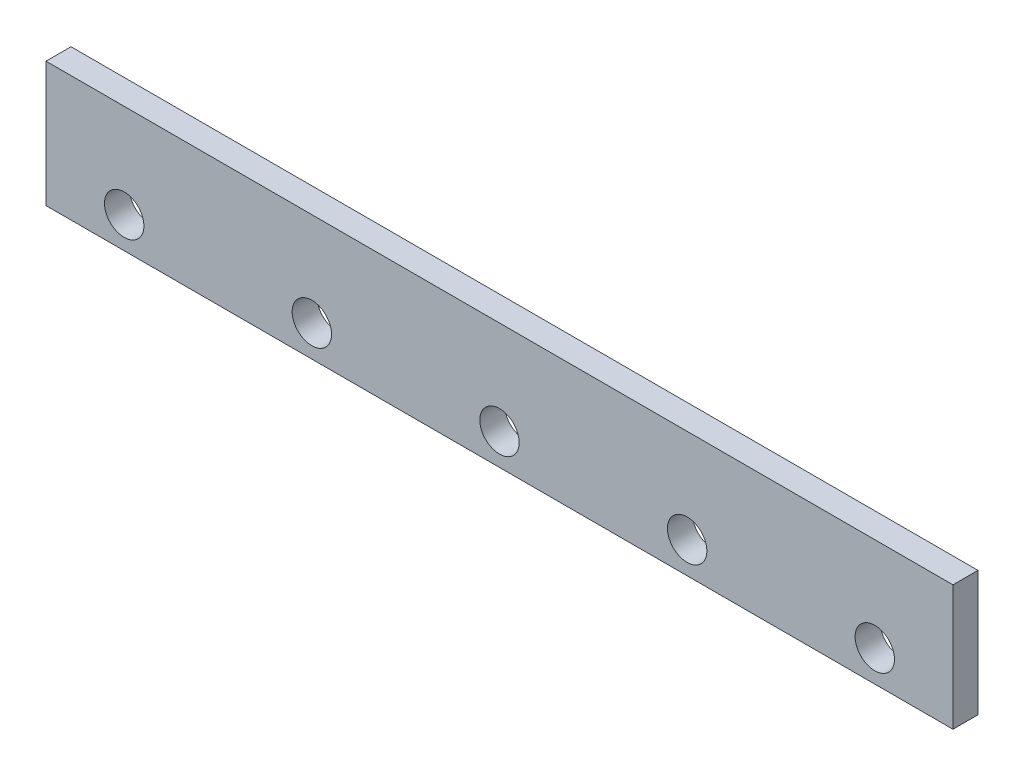
from build123d import *

# Parameters (mm, degrees)
SKETCH1_W           = 580
SKETCH1_H           = 80
BOSS_EXTRUDE1_DEPTH = 16
SKETCH2_R           = 12.6
CUT_EXTRUDE1_DEPTH  = 16


with BuildPart() as part:
    # Sketch1 → Boss-Extrude1 (new body)
    with BuildSketch(Plane.XY):
        with Locations((290, 40)):
            Rectangle(SKETCH1_W, SKETCH1_H)
    extrude(amount=BOSS_EXTRUDE1_DEPTH)

    # Sketch2 → Cut-Extrude1 (cut)
    with BuildSketch(Plane.XY.offset(16)):
        with Locations((50, 20)):
            Circle(SKETCH2_R)
        with Locations((170, 20)):
            Circle(SKETCH2_R)
        with Locations((290, 20)):
            Circle(SKETCH2_R)
        with Locations((410, 20)):
            Circle(SKETCH2_R)
        with Locations((530, 20)):
            Circle(SKETCH2_R)
    extrude(amount=-CUT_EXTRUDE1_DEPTH, mode=Mode.SUBTRACT)


solid = part.part
